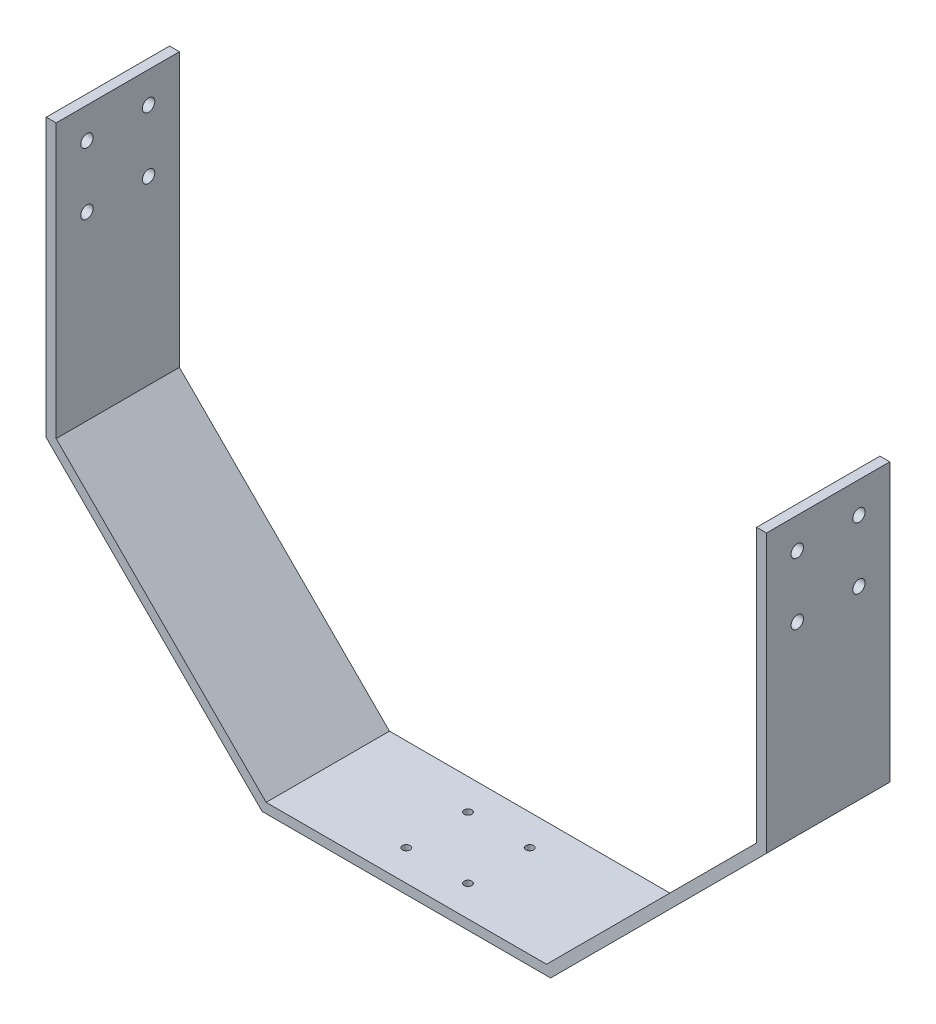
from build123d import *

# Parameters (mm, degrees)
BOSS_EXTRUDE2_DEPTH          = 50.8
F_10_CLEARANCE_HOLE1_D       = 5.1054
F_10_CLEARANCE_HOLE1_DEPTH   = 4.064
F_1_8_0_125_DIAMETER_HOLE1_D = 3.175


with BuildPart() as part:
    # Sketch1 → Boss-Extrude2 (new body)
    with BuildSketch(Plane.XY):
        Polygon((0, 203.2), (0, 88.9), (88.9, 0), (207.772, 0), (296.672, 88.9), (296.672, 203.2), (292.608, 203.2), (292.608, 90.583363917), (206.088636083, 4.064), (90.583363917, 4.064), (4.064, 90.583363917), (4.064, 203.2), align=None)
    extrude(amount=BOSS_EXTRUDE2_DEPTH)

    # #10 Clearance Hole1
    with Locations(Plane(origin=(4.064, 0, 0), x_dir=(0, 0, -1), z_dir=(1, 0, 0))):
        with Locations((-38.1, 190.5), (-12.7, 165.1), (-38.1, 165.1), (-12.7, 190.5)):
            f_10_clearance_hole1 = Hole(F_10_CLEARANCE_HOLE1_D / 2, depth=F_10_CLEARANCE_HOLE1_DEPTH)

    # Mirror1: #10 Clearance Hole1 across plane
    add(f_10_clearance_hole1.mirror(Plane(origin=(148.336, 0, 0), x_dir=(0, 0, 1), z_dir=(1, 0, 0))), mode=Mode.SUBTRACT)

    # 1/8 (0.125) Diameter Hole1 (through all)
    with Locations(Plane(origin=(0, 4.064, 0), x_dir=(1, 0, 0), z_dir=(0, 1, 0))):
        with Locations((135.636, -38.1), (161.036, -12.7), (135.636, -12.7), (161.036, -38.1)):
            Hole(F_1_8_0_125_DIAMETER_HOLE1_D / 2)


solid = part.part
